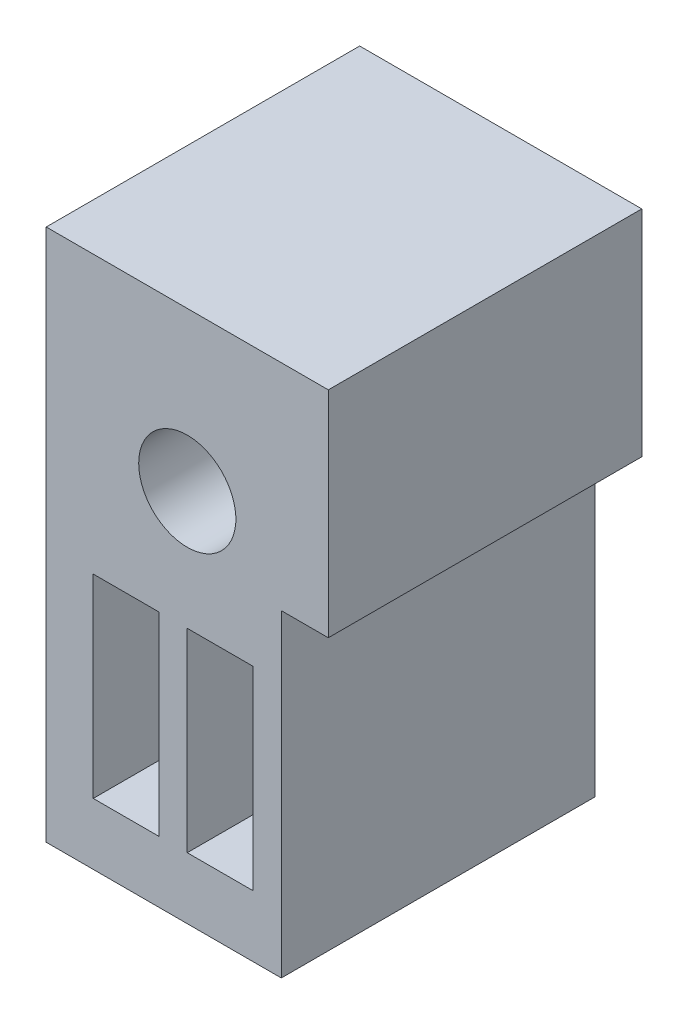
from build123d import *

# Parameters (mm, degrees)
SKIZZE2_R                       = 1.55
SKIZZE2_W                       = 2.1
SKIZZE2_H                       = 6.2
AUFSATZ_LINEAR_AUSTRAGEN1_DEPTH = 10


with BuildPart() as part:
    # Skizze2 → Aufsatz-Linear austragen1 (new body)
    with BuildSketch(Plane(origin=(0, 0, -20.169507331), x_dir=(-1, 0, 0), z_dir=(0, 0, -1))):
        Polygon((-22.148061032, 15.226980034), (-19.148061032, 15.226980034), (-16.448061032, 15.226980034), (-16.148061032, 15.226980034), (-14.648061032, 15.226980034), (-14.648061032, 25.377216735), (-14.648061032, 32.226980034), (-19.148061032, 32.226980034), (-23.648061032, 32.226980034), (-23.648061032, 25.377216735), (-22.148061032, 25.377216735), align=None)
        with Locations((-19.148061032, 27.176743334)):
            Circle(SKIZZE2_R, mode=Mode.SUBTRACT)
        with Locations((-17.198061032, 20.288222167)):
            Rectangle(SKIZZE2_W, SKIZZE2_H, mode=Mode.SUBTRACT)
        with Locations((-20.196983303, 20.288222167)):
            Rectangle(SKIZZE2_W, SKIZZE2_H, mode=Mode.SUBTRACT)
    extrude(amount=AUFSATZ_LINEAR_AUSTRAGEN1_DEPTH)


solid = part.part
